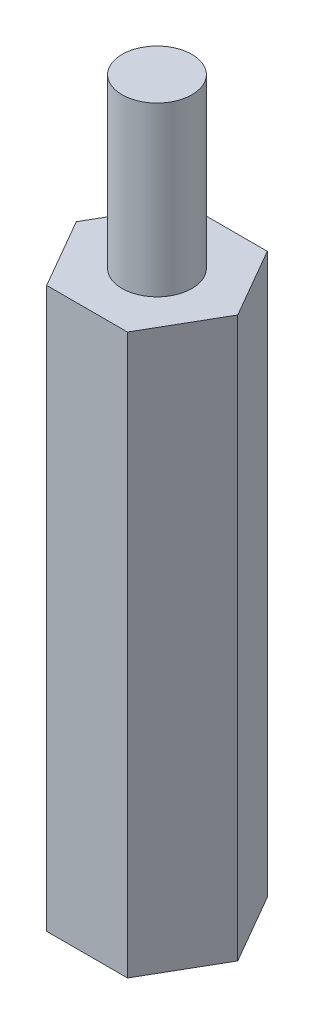
from build123d import *

# Parameters (mm, degrees)
BOSS_EXTRUDE1_DEPTH = 20
SKETCH2_R           = 1.25
BOSS_EXTRUDE2_DEPTH = 6
SKETCH3_R           = 1.25
CUT_EXTRUDE1_DEPTH  = 6


with BuildPart() as part:
    # Sketch1 → Boss-Extrude1 (new body)
    with BuildSketch(Plane(origin=(0, 0, 0), x_dir=(1, 0, 0), z_dir=(0, 1, 0))):
        Polygon((-2.886751346, 0), (-1.443375673, -2.5), (1.443375673, -2.5), (2.886751346, 0), (1.443375673, 2.5), (-1.443375673, 2.5), align=None)
    extrude(amount=BOSS_EXTRUDE1_DEPTH)

    # Sketch2 → Boss-Extrude2 (add)
    with BuildSketch(Plane(origin=(0, 20, 0), x_dir=(1, 0, 0), z_dir=(0, 1, 0))):
        Circle(SKETCH2_R)
    extrude(amount=BOSS_EXTRUDE2_DEPTH)

    # Sketch3 → Cut-Extrude1 (cut)
    with BuildSketch(Plane.XZ):
        Circle(SKETCH3_R)
    extrude(amount=-CUT_EXTRUDE1_DEPTH, mode=Mode.SUBTRACT)


solid = part.part
